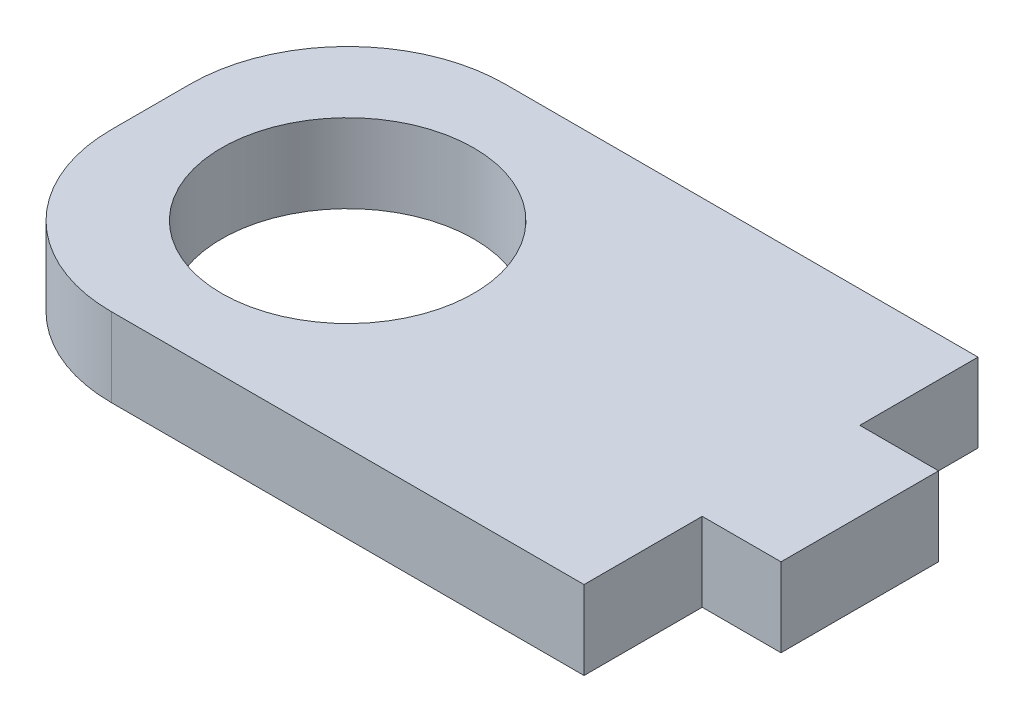
from build123d import *

# Parameters (mm, degrees)
ESQUISSE1_R        = 8
BOSS_EXTRU_1_DEPTH = 5
CONG_1_R           = 10


with BuildPart() as part:
    # Esquisse1 → Boss.-Extru.1 (new body)
    with BuildSketch(Plane(origin=(0, 0, 0), x_dir=(1, 0, 0), z_dir=(0, 1, 0))):
        Polygon((40, -7.5), (45, -7.5), (45, -17.5), (40, -17.5), (40, -25), (0, -25), (0, 0), (40, 0), align=None)
        with Locations((12.5, -12.5)):
            Circle(ESQUISSE1_R, mode=Mode.SUBTRACT)
    extrude(amount=BOSS_EXTRU_1_DEPTH)

    # Congé1
    cong_1_edges = [part.edges().sort_by_distance(p)[0] for p in [
        (0, 2.5, 0),
        (0, 2.5, 25),
    ]]
    fillet(cong_1_edges, radius=CONG_1_R)


solid = part.part
